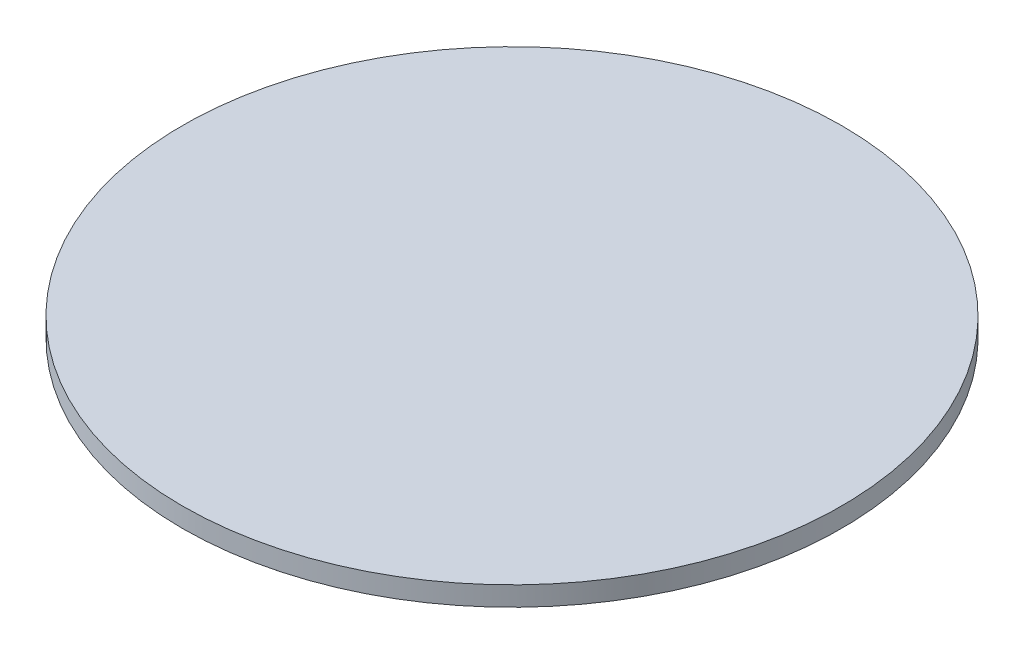
from build123d import *

# Parameters (mm, degrees)
SKETCH_1_R      = 25.4
EXTRUDE_1_DEPTH = 1.5


with BuildPart() as part:
    # 草图1 → 凸台-拉伸1 (new body)
    with BuildSketch(Plane(origin=(0, 0, 0), x_dir=(1, 0, 0), z_dir=(0, 1, 0))):
        with Locations(Location((0, 0, 0), (0, 0, 270))):  # turned: the seam where the file's is
            Circle(SKETCH_1_R)
    extrude(amount=EXTRUDE_1_DEPTH)


solid = part.part
